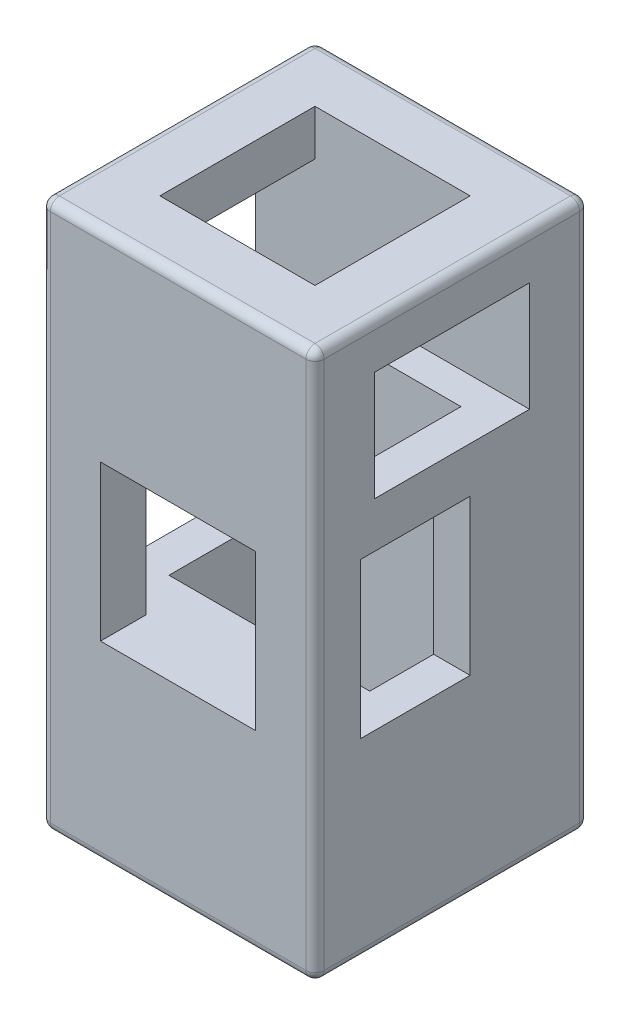
from build123d import *

# Parameters (mm, degrees)
SKETCH_1_W          = 30
SKETCH_1_H          = 30
EXTRUDE_2_DEPTH     = 60
SKETCH_2_W          = 22
SKETCH_2_H          = 10
CUT_EXTRUDE_1_DEPTH = 47
SKETCH_3_W          = 17
SKETCH_3_H          = 12
CUT_EXTRUDE_2_DEPTH = 31
SKETCH_5_W          = 17
SKETCH_5_H          = 17
CUT_EXTRUDE_3_DEPTH = 5
SKETCH_6_W          = 12
SKETCH_6_H          = 17
CUT_EXTRUDE_4_DEPTH = 31
SKETCH_7_W          = 17
SKETCH_7_H          = 17
CUT_EXTRUDE_5_DEPTH = 5
FILLET_1_R          = 1
FILLET_2_R          = 1
FILLET_3_R          = 1
FILLET_4_R          = 1
FILLET_5_R          = 1


with BuildPart() as part:
    # ｽｹｯﾁ1 → ﾎﾞｽ - 押し出し2 (new body)
    with BuildSketch(Plane(origin=(0, 0, 0), x_dir=(1, 0, 0), z_dir=(0, 1, 0))):
        Rectangle(SKETCH_1_W, SKETCH_1_H)
    extrude(amount=EXTRUDE_2_DEPTH)

    # ｽｹｯﾁ2 → ｶｯﾄ - 押し出し1 (cut)
    with BuildSketch(Plane.XZ):
        Rectangle(SKETCH_2_W, SKETCH_2_H)
    extrude(amount=-CUT_EXTRUDE_1_DEPTH, mode=Mode.SUBTRACT)

    # ｽｹｯﾁ3 → ｶｯﾄ - 押し出し2 (cut, through all)
    with BuildSketch(Plane(origin=(15, 0, 0), x_dir=(0, 0, -1), z_dir=(1, 0, 0))):
        with Locations((0, 49)):
            Rectangle(SKETCH_3_W, SKETCH_3_H)
    extrude(amount=-CUT_EXTRUDE_2_DEPTH, mode=Mode.SUBTRACT)

    # ｽｹｯﾁ5 → ｶｯﾄ - 押し出し3 (cut)
    with BuildSketch(Plane(origin=(0, 60, 0), x_dir=(1, 0, 0), z_dir=(0, 1, 0))):
        Rectangle(SKETCH_5_W, SKETCH_5_H)
    extrude(amount=-CUT_EXTRUDE_3_DEPTH, mode=Mode.SUBTRACT)

    # ｽｹｯﾁ6 → ｶｯﾄ - 押し出し4 (cut, through all)
    with BuildSketch(Plane(origin=(15, 0, 0), x_dir=(0, 0, -1), z_dir=(1, 0, 0))):
        with Locations((-4, 29.5)):
            Rectangle(SKETCH_6_W, SKETCH_6_H)
    extrude(amount=-CUT_EXTRUDE_4_DEPTH, mode=Mode.SUBTRACT)

    # ｽｹｯﾁ7 → ｶｯﾄ - 押し出し5 (cut)
    with BuildSketch(Plane.XY.offset(15)):
        with Locations((0, 29.5)):
            Rectangle(SKETCH_7_W, SKETCH_7_H)
    extrude(amount=-CUT_EXTRUDE_5_DEPTH, mode=Mode.SUBTRACT)

    # ﾌｨﾚｯﾄ1
    fillet_1_edges = [part.edges().sort_by_distance(p)[0] for p in [
        (15, 30, 15),
    ]]
    fillet(fillet_1_edges, radius=FILLET_1_R)

    # ﾌｨﾚｯﾄ2
    fillet_2_edges = [part.edges().sort_by_distance(p)[0] for p in [
        (15, 0, -0.5),
        (14.707106781, 0, 14.707106781),
        (-0.5, 0, 15),
    ]]
    fillet(fillet_2_edges, radius=FILLET_2_R)

    # ﾌｨﾚｯﾄ3
    fillet_3_edges = [part.edges().sort_by_distance(p)[0] for p in [
        (-0.5, 0, -15),
        (14.707106781, 0.292893219, -15),
        (15, 30.5, -15),
    ]]
    fillet(fillet_3_edges, radius=FILLET_3_R)

    # ﾌｨﾚｯﾄ4
    fillet_4_edges = [part.edges().sort_by_distance(p)[0] for p in [
        (15, 60, 0),
        (14.707106781, 60, 14.707106781),
        (-0.5, 60, -15),
        (14.707106781, 60, -14.707106781),
        (-0.5, 60, 15),
    ]]
    fillet(fillet_4_edges, radius=FILLET_4_R)

    # ﾌｨﾚｯﾄ5
    fillet_5_edges = [part.edges().sort_by_distance(p)[0] for p in [
        (-15, 0.292893219, 14.707106781),
        (-15, 0, 0),
        (-15, 0.292893219, -14.707106781),
        (-15, 60, 0),
        (-15, 30, 15),
        (-15, 30, -15),
        (-15, 59.707106781, -14.707106781),
        (-15, 59.707106781, 14.707106781),
    ]]
    fillet(fillet_5_edges, radius=FILLET_5_R)


solid = part.part
